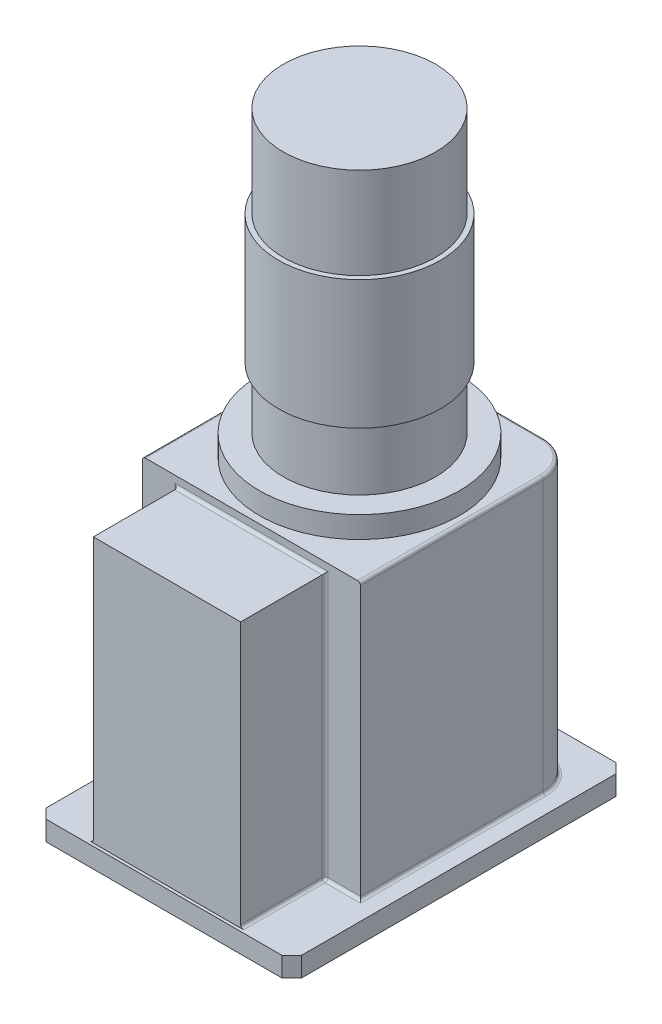
from build123d import *

# Parameters (mm, degrees)
CROQUIS1_W              = 260
CROQUIS1_H              = 340
SALIENTE_EXTRUIR1_DEPTH = 20
CROQUIS2_W              = 222
CROQUIS2_H              = 221
SALIENTE_EXTRUIR2_DEPTH = 280
CROQUIS3_W              = 150
CROQUIS3_H              = 86
SALIENTE_EXTRUIR3_DEPTH = 270
CHAFL_N1_SIZE           = 10
REDONDEO1_R             = 35
REDONDEO3_R             = 3


with BuildPart() as part:
    # Croquis1 → Saliente-Extruir1 (new body)
    with BuildSketch(Plane(origin=(0, 0, 0), x_dir=(1, 0, 0), z_dir=(0, 1, 0))):
        Rectangle(CROQUIS1_W, CROQUIS1_H)
    extrude(amount=SALIENTE_EXTRUIR1_DEPTH)

    # Croquis2 → Saliente-Extruir2 (add)
    with BuildSketch(Plane(origin=(0, 20, 0), x_dir=(1, 0, 0), z_dir=(0, 1, 0))):
        with Locations((0, 29.5)):
            Rectangle(CROQUIS2_W, CROQUIS2_H)
    extrude(amount=SALIENTE_EXTRUIR2_DEPTH)

    # Croquis3 → Saliente-Extruir3 (add)
    with BuildSketch(Plane(origin=(0, 20, 0), x_dir=(1, 0, 0), z_dir=(0, 1, 0))):
        with Locations((0, -124)):
            Rectangle(CROQUIS3_W, CROQUIS3_H)
    extrude(amount=SALIENTE_EXTRUIR3_DEPTH)

    # Chaflán1
    chafl_n1_edges = [part.edges().sort_by_distance(p)[0] for p in [
        (130, 10, 170),
        (-130, 10, 170),
        (-130, 10, -170),
        (130, 10, -170),
    ]]
    chamfer(chafl_n1_edges, length=CHAFL_N1_SIZE)

    # Redondeo1
    redondeo1_edges = [part.edges().sort_by_distance(p)[0] for p in [
        (-111, 160, -140),
        (111, 160, -140),
    ]]
    fillet(redondeo1_edges, radius=REDONDEO1_R)

    # Redondeo3
    redondeo3_edges = [part.edges().sort_by_distance(p)[0] for p in [
        (-93, 20, 81),
        (111, 20, -12),
        (111, 300, -12),
        (93, 20, 81),
        (-75, 20, 124),
        (-75, 155, 81),
        (75, 20, 124),
        (75, 155, 81),
        (0, 290, 81),
        (0, 20, -140),
        (0, 300, -140),
        (-111, 300, -12),
        (-100.748737342, 300, -129.748737342),
        (100.748737342, 300, -129.748737342),
        (-111, 20, -12),
        (100.748737342, 20, -129.748737342),
        (-100.748737342, 20, -129.748737342),
    ]]
    fillet(redondeo3_edges, radius=REDONDEO3_R)

    # Croquis4 → Revolución1 (revolve)
    with BuildSketch(Plane.ZY.offset(-0.86)):
        Polygon((-28.14, 300), (-130, 300), (-130, 322), (-105.64, 322), (-105.64, 384.5), (-110.64, 384.5), (-110.64, 515.5), (-105.64, 515.5), (-105.64, 608.5), (-28.14, 608.5), align=None)
    revolve(axis=Axis((0.86, 300, -28.14), (0, 1, 0)))


solid = part.part
